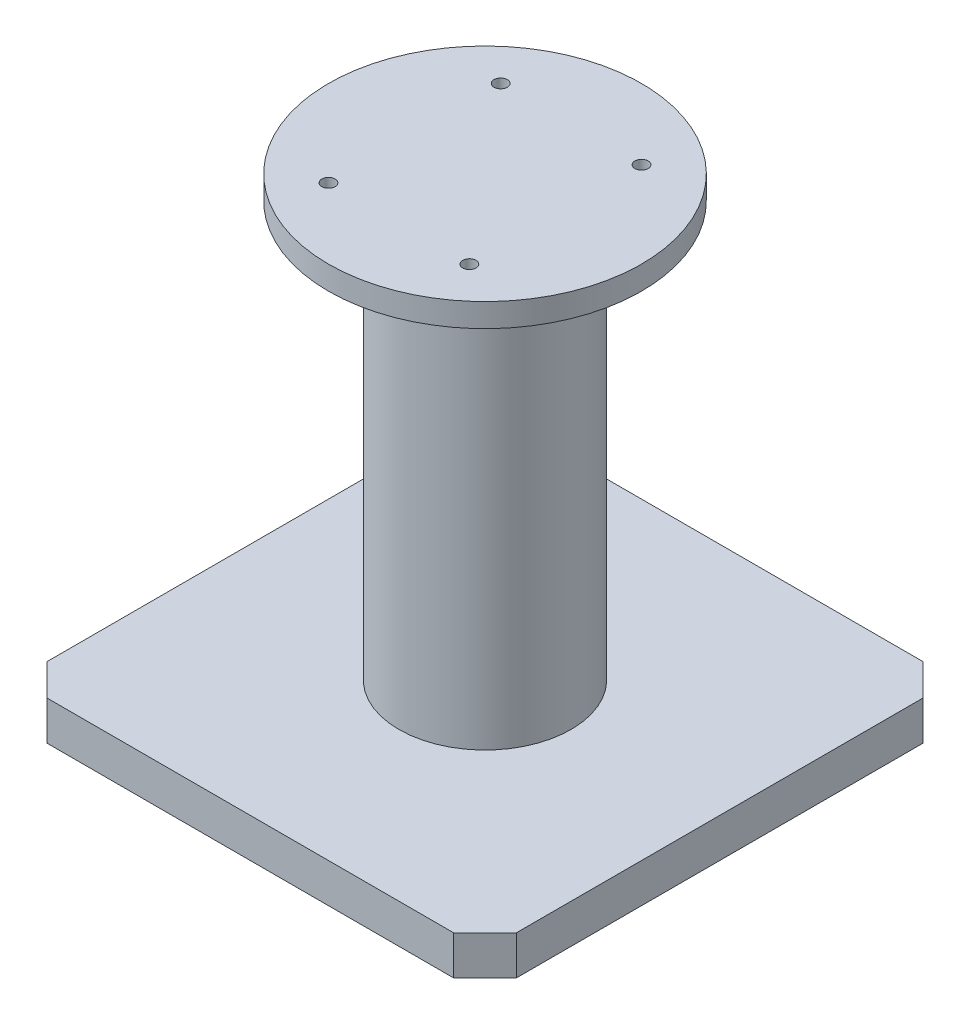
from build123d import *

# Parameters (mm, degrees)
BOSS_EXTRUDE1_DEPTH = 25
SKETCH2_R           = 55
BOSS_EXTRUDE2_DEPTH = 265
SKETCH3_R           = 100
BOSS_EXTRUDE3_DEPTH = 15
SKETCH4_R           = 4.25
CUT_EXTRUDE1_DEPTH  = 15


with BuildPart() as part:
    # Sketch1 → Boss-Extrude1 (new body)
    with BuildSketch(Plane(origin=(0, 0, 0), x_dir=(1, 0, 0), z_dir=(0, 1, 0))):
        Polygon((-150, 130), (-130, 150), (130, 150), (150, 130), (150, -130), (130, -150), (-130, -150), (-150, -130), align=None)
    extrude(amount=BOSS_EXTRUDE1_DEPTH)

    # Sketch2 → Boss-Extrude2 (add)
    with BuildSketch(Plane(origin=(0, 25, 0), x_dir=(1, 0, 0), z_dir=(0, 1, 0))):
        Circle(SKETCH2_R)
    extrude(amount=BOSS_EXTRUDE2_DEPTH)

    # Sketch3 → Boss-Extrude3 (add)
    with BuildSketch(Plane(origin=(0, 290, 0), x_dir=(1, 0, 0), z_dir=(0, 1, 0))):
        Circle(SKETCH3_R)
    extrude(amount=BOSS_EXTRUDE3_DEPTH)

    # Sketch4 → Cut-Extrude1 (cut)
    with BuildSketch(Plane(origin=(0, 305, 0), x_dir=(1, 0, 0), z_dir=(0, 1, 0))):
        with Locations((-45, 55)):
            Circle(SKETCH4_R)
        with Locations((45, 55)):
            Circle(SKETCH4_R)
        with Locations((45, -55)):
            Circle(SKETCH4_R)
        with Locations((-45, -55)):
            Circle(SKETCH4_R)
    extrude(amount=-CUT_EXTRUDE1_DEPTH, mode=Mode.SUBTRACT)


solid = part.part
